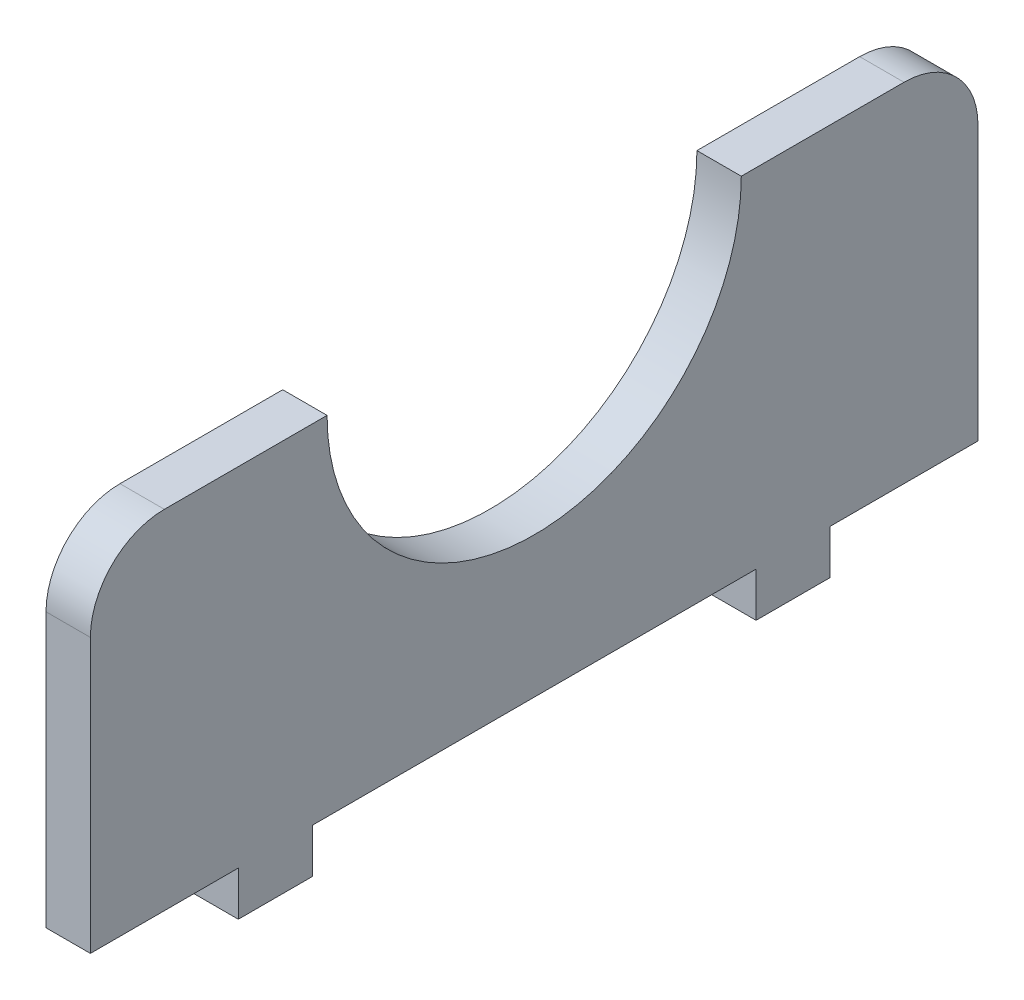
from build123d import *

# Parameters (mm, degrees)
BOSS_EXTRUDE1_DEPTH = 3
FILLET1_R           = 5
SKETCH3_W           = 3
SKETCH3_H           = 5
BOSS_EXTRUDE2_DEPTH = 3


with BuildPart() as part:
    # Sketch1 → Boss-Extrude1 (new body)
    with BuildSketch(Plane(origin=(0, 0, 0), x_dir=(0, 0, -1), z_dir=(1, 0, 0))):
        with BuildLine():
            Line((-14, 11.75), (-30, 11.75))
            Line((-30, 11.75), (-30, -11.75))
            Line((-30, -11.75), (30, -11.75))
            Line((30, -11.75), (30, 11.75))
            Line((30, 11.75), (14, 11.75))
            ThreePointArc((14, 11.75), (0, -2.25), (-14, 11.75))
        make_face()
    extrude(amount=BOSS_EXTRUDE1_DEPTH)

    # Fillet1
    fillet1_edges = [part.edges().sort_by_distance(p)[0] for p in [
        (1.5, 11.75, 30),
        (1.5, 11.75, -30),
    ]]
    fillet(fillet1_edges, radius=FILLET1_R)

    # Sketch3 → Boss-Extrude2 (add)
    with BuildSketch(Plane.XZ.offset(11.75)):
        with Locations((1.5, 17.5)):
            Rectangle(SKETCH3_W, SKETCH3_H)
    boss_extrude2 = extrude(amount=BOSS_EXTRUDE2_DEPTH)

    # Mirror3: Boss-Extrude2 across plane
    add(boss_extrude2.mirror(Plane.XY))


solid = part.part
